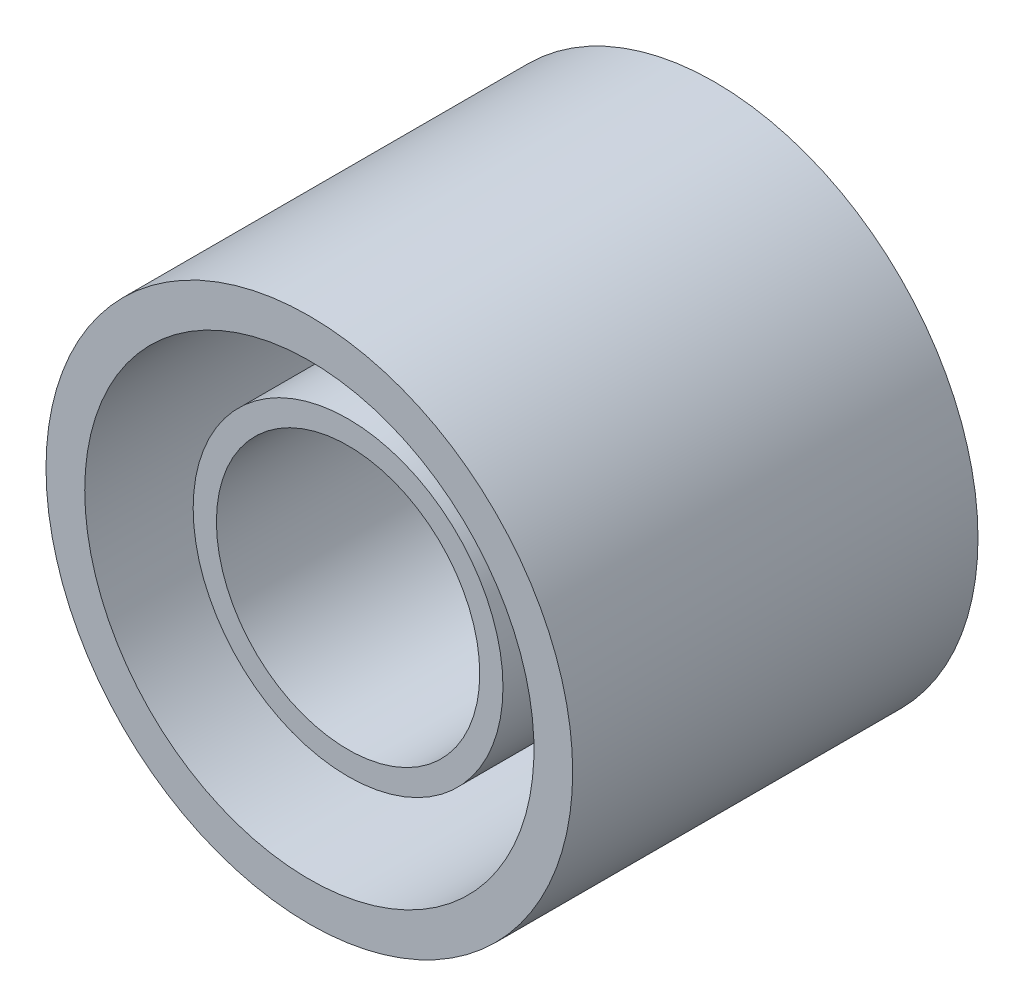
from build123d import *


with BuildPart() as part:
    # Sketch2 → Revolve1 (revolve)
    with BuildSketch(Plane.ZY.offset(-259.301545348)):
        Polygon((0, -133.573704322), (5, -133.573704322), (5, -131.573704322), (47.330517131, -131.573704322), (47.330517131, -128.573704322), (5, -128.573704322), (5, -119.573704322), (52.330517131, -119.573704322), (52.330517131, -114.573704322), (0, -114.573704322), align=None)
    revolve(axis=Axis((259.301545348, -148.573704322, -1.12), (0, 0, 1)))


solid = part.part
